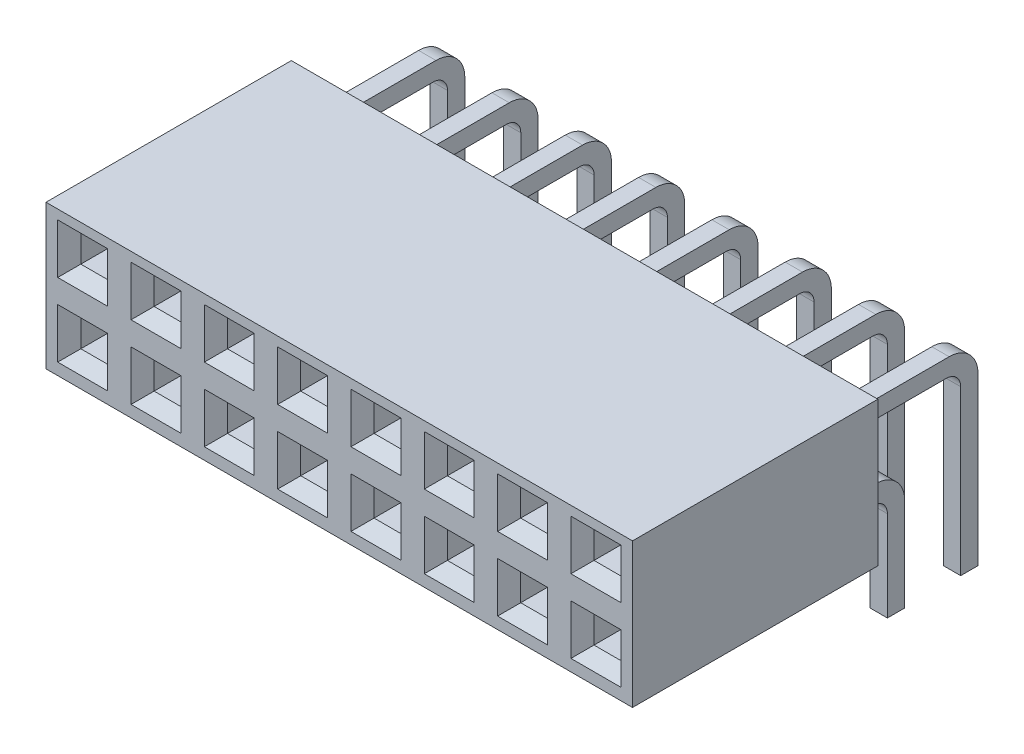
from build123d import *

# Parameters (mm, degrees)
SKETCH_1_W             = 20.32
SKETCH_1_H             = 5
EXTRUDE_1_DEPTH        = 8.5
SKETCH_2_W             = 0.928275102
SKETCH_2_H             = 0.928275102
CUT_EXTRUDE_1_DEPTH    = 6
CHAMFER_1_SIZE         = 0.4
EXTRUDE_2_DEPTH        = 0.3
PATTERN_LINEAR_1_COUNT = 8
PATTERN_LINEAR_1_PITCH = 2.54
CHAMFER_2_SIZE         = 0.2


with BuildPart() as part:
    # Эскиз1 → Бобышка-Вытянуть1 (new body)
    with BuildSketch(Plane.XY):
        Rectangle(SKETCH_1_W, SKETCH_1_H)
    extrude(amount=-EXTRUDE_1_DEPTH)

    # Эскиз2 → Вырез-Вытянуть1 (cut)
    with BuildSketch(Plane.XY):
        with Locations((-8.89, -1.23)):
            Rectangle(SKETCH_2_W, SKETCH_2_H)
        with Locations((-6.35, -1.23)):
            Rectangle(SKETCH_2_W, SKETCH_2_H)
        with Locations((-3.81, -1.23)):
            Rectangle(SKETCH_2_W, SKETCH_2_H)
        with Locations((-1.27, -1.23)):
            Rectangle(SKETCH_2_W, SKETCH_2_H)
        with Locations((1.27, -1.23)):
            Rectangle(SKETCH_2_W, SKETCH_2_H)
        with Locations((3.81, -1.23)):
            Rectangle(SKETCH_2_W, SKETCH_2_H)
        with Locations((6.35, -1.23)):
            Rectangle(SKETCH_2_W, SKETCH_2_H)
        with Locations((8.89, -1.23)):
            Rectangle(SKETCH_2_W, SKETCH_2_H)
        with Locations((-6.35, 1.31)):
            Rectangle(SKETCH_2_W, SKETCH_2_H)
        with Locations((-3.81, 1.31)):
            Rectangle(SKETCH_2_W, SKETCH_2_H)
        with Locations((-1.27, 1.31)):
            Rectangle(SKETCH_2_W, SKETCH_2_H)
        with Locations((1.27, 1.31)):
            Rectangle(SKETCH_2_W, SKETCH_2_H)
        with Locations((3.81, 1.31)):
            Rectangle(SKETCH_2_W, SKETCH_2_H)
        with Locations((6.35, 1.31)):
            Rectangle(SKETCH_2_W, SKETCH_2_H)
        with Locations((8.89, 1.31)):
            Rectangle(SKETCH_2_W, SKETCH_2_H)
        with Locations((-8.89, 1.31)):
            Rectangle(SKETCH_2_W, SKETCH_2_H)
    extrude(amount=-CUT_EXTRUDE_1_DEPTH, mode=Mode.SUBTRACT)

    # Фаска1
    chamfer_1_edges = [part.edges().sort_by_distance(p)[0] for p in [
        (8.89, 0.845862449, 0),
        (9.354137551, 1.31, 0),
        (8.89, 1.774137551, 0),
        (8.425862449, 1.31, 0),
        (6.35, 0.845862449, 0),
        (6.814137551, 1.31, 0),
        (6.35, 1.774137551, 0),
        (5.885862449, 1.31, 0),
        (3.81, 0.845862449, 0),
        (4.274137551, 1.31, 0),
        (3.81, 1.774137551, 0),
        (3.345862449, 1.31, 0),
        (1.27, 0.845862449, 0),
        (1.734137551, 1.31, 0),
        (1.27, 1.774137551, 0),
        (0.805862449, 1.31, 0),
        (-1.27, 0.845862449, 0),
        (-0.805862449, 1.31, 0),
        (-1.27, 1.774137551, 0),
        (-1.734137551, 1.31, 0),
        (-3.81, 0.845862449, 0),
        (-3.345862449, 1.31, 0),
        (-3.81, 1.774137551, 0),
        (-4.274137551, 1.31, 0),
        (-8.425862449, -1.23, 0),
        (-8.89, -0.765862449, 0),
        (-9.354137551, -1.23, 0),
        (-8.89, -1.694137551, 0),
        (3.81, -1.694137551, 0),
        (4.274137551, -1.23, 0),
        (3.81, -0.765862449, 0),
        (3.345862449, -1.23, 0),
        (6.35, -1.694137551, 0),
        (6.814137551, -1.23, 0),
        (6.35, -0.765862449, 0),
        (5.885862449, -1.23, 0),
        (8.89, -1.694137551, 0),
        (9.354137551, -1.23, 0),
        (8.89, -0.765862449, 0),
        (8.425862449, -1.23, 0),
        (-6.35, 0.845862449, 0),
        (-5.885862449, 1.31, 0),
        (-6.35, 1.774137551, 0),
        (-6.814137551, 1.31, 0),
        (1.27, -1.694137551, 0),
        (1.734137551, -1.23, 0),
        (1.27, -0.765862449, 0),
        (0.805862449, -1.23, 0),
        (-1.27, -1.694137551, 0),
        (-0.805862449, -1.23, 0),
        (-1.27, -0.765862449, 0),
        (-1.734137551, -1.23, 0),
        (-3.81, -1.694137551, 0),
        (-3.345862449, -1.23, 0),
        (-3.81, -0.765862449, 0),
        (-4.274137551, -1.23, 0),
        (-6.35, -1.694137551, 0),
        (-5.885862449, -1.23, 0),
        (-6.35, -0.765862449, 0),
        (-6.814137551, -1.23, 0),
        (-8.89, 0.845862449, 0),
        (-8.425862449, 1.31, 0),
        (-8.89, 1.774137551, 0),
        (-9.354137551, 1.31, 0),
    ]]
    chamfer(chamfer_1_edges, length=CHAMFER_1_SIZE)

    # Эскиз3 → Бобышка-Вытянуть2 (add, symmetric)
    with BuildSketch(Plane.ZY.offset(8.89)):
        with BuildLine():
            Line((-8.5, 1.57), (-11.94, 1.57))
            ThreePointArc((-11.94, 1.57), (-12.647106781, 1.277106781), (-12.94, 0.57))
            Line((-12.94, 0.57), (-12.94, -5.4))
            Line((-12.94, -5.4), (-12.34, -5.4))
            Line((-12.34, -5.4), (-12.34, 0.47))
            ThreePointArc((-12.34, 0.47), (-12.193553391, 0.823553391), (-11.84, 0.97))
            Line((-11.84, 0.97), (-8.5, 0.97))
            Line((-8.5, 0.97), (-8.5, 1.57))
        make_face()
        with BuildLine():
            Line((-8.5, -0.97), (-9.4, -0.97))
            ThreePointArc((-9.4, -0.97), (-10.107106781, -1.262893219), (-10.4, -1.97))
            Line((-10.4, -1.97), (-10.4, -5.4))
            Line((-10.4, -5.4), (-9.8, -5.4))
            Line((-9.8, -5.4), (-9.8, -2.07))
            ThreePointArc((-9.8, -2.07), (-9.653553391, -1.716446609), (-9.3, -1.57))
            Line((-9.3, -1.57), (-8.5, -1.57))
            Line((-8.5, -1.57), (-8.5, -0.97))
        make_face()
    extrude_2 = extrude(amount=EXTRUDE_2_DEPTH, both=True)

    # Линейный массив1: Бобышка-Вытянуть2 ×8
    with Locations(*[(i * PATTERN_LINEAR_1_PITCH, 0, 0) for i in range(1, PATTERN_LINEAR_1_COUNT)]):
        add(extrude_2)

    # Фаска2
    chamfer_2_edges = [part.edges().sort_by_distance(p)[0] for p in [
        (-8.59, -5.4, -12.64),
        (-8.89, -5.4, -12.94),
        (-8.89, -5.4, -12.34),
        (-9.19, -5.4, -12.64),
        (-8.59, -5.4, -10.1),
        (-8.89, -5.4, -10.4),
        (-8.89, -5.4, -9.8),
        (-9.19, -5.4, -10.1),
        (-6.05, -5.4, -12.64),
        (-6.35, -5.4, -12.94),
        (-6.35, -5.4, -12.34),
        (-6.65, -5.4, -12.64),
        (-6.05, -5.4, -10.1),
        (-6.35, -5.4, -10.4),
        (-6.35, -5.4, -9.8),
        (-6.65, -5.4, -10.1),
        (-3.51, -5.4, -12.64),
        (-3.81, -5.4, -12.94),
        (-3.81, -5.4, -12.34),
        (-4.11, -5.4, -12.64),
        (-3.51, -5.4, -10.1),
        (-3.81, -5.4, -10.4),
        (-3.81, -5.4, -9.8),
        (-4.11, -5.4, -10.1),
        (-0.97, -5.4, -12.64),
        (-1.27, -5.4, -12.94),
        (-1.27, -5.4, -12.34),
        (-1.57, -5.4, -12.64),
        (-0.97, -5.4, -10.1),
        (-1.27, -5.4, -10.4),
        (-1.27, -5.4, -9.8),
        (-1.57, -5.4, -10.1),
        (1.57, -5.4, -12.64),
        (1.27, -5.4, -12.94),
        (1.27, -5.4, -12.34),
        (0.97, -5.4, -12.64),
        (1.57, -5.4, -10.1),
        (1.27, -5.4, -10.4),
        (1.27, -5.4, -9.8),
        (0.97, -5.4, -10.1),
        (4.11, -5.4, -12.64),
        (3.81, -5.4, -12.94),
        (3.81, -5.4, -12.34),
        (3.51, -5.4, -12.64),
        (4.11, -5.4, -10.1),
        (3.81, -5.4, -10.4),
        (3.81, -5.4, -9.8),
        (3.51, -5.4, -10.1),
        (6.65, -5.4, -12.64),
        (6.35, -5.4, -12.94),
        (6.35, -5.4, -12.34),
        (6.05, -5.4, -12.64),
        (6.65, -5.4, -10.1),
        (6.35, -5.4, -10.4),
        (6.35, -5.4, -9.8),
        (6.05, -5.4, -10.1),
        (9.19, -5.4, -12.64),
        (8.89, -5.4, -12.94),
        (8.89, -5.4, -12.34),
        (8.59, -5.4, -12.64),
        (9.19, -5.4, -10.1),
        (8.89, -5.4, -10.4),
        (8.89, -5.4, -9.8),
        (8.59, -5.4, -10.1),
    ]]
    chamfer(chamfer_2_edges, length=CHAMFER_2_SIZE)


solid = part.part
